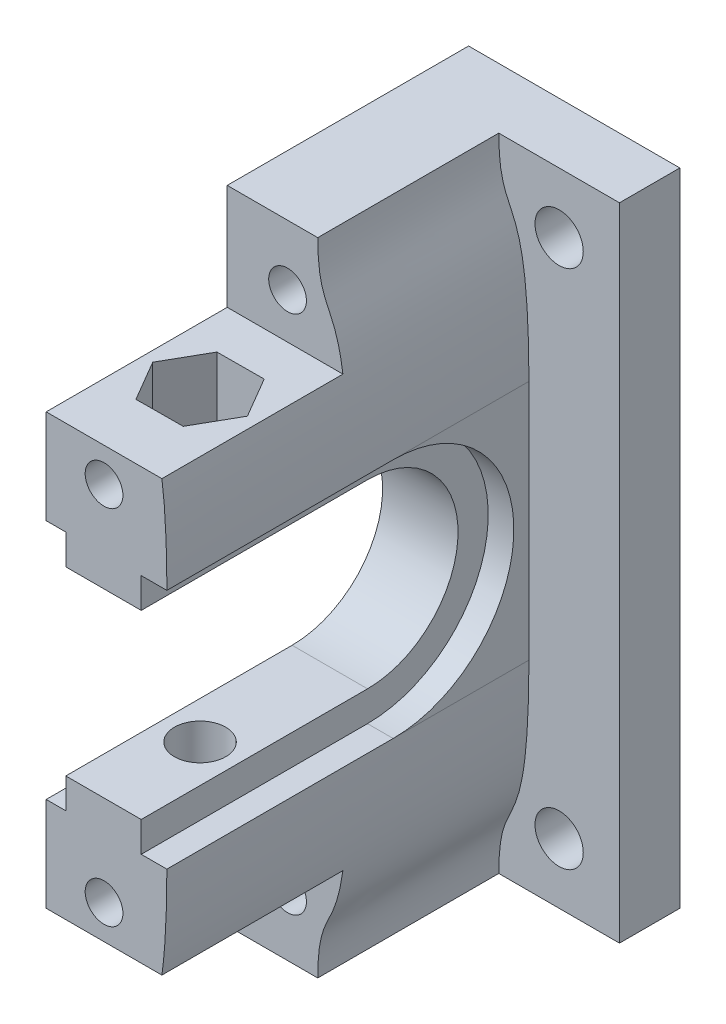
from build123d import *

# Parameters (mm, degrees)
ESQUISSE1_W                                        = 14
ESQUISSE1_H                                        = 42.5
ESQUISSE1_R                                        = 1.6
BOSS_EXTRU_1_DEPTH                                 = 4
ESQUISSE2_W                                        = 8
ESQUISSE2_H                                        = 42.5
BOSS_EXTRU_2_DEPTH                                 = 24
ENL_V_MAT_EXTRU_1_DEPTH                            = 9
ENL_V_START                                        = -1.7
ENL_V_MAT_EXTRU_3_DEPTH                            = 1.7
ENL_V_START_2                                      = -1.3
ENL_V_MAT_EXTRU_4_DEPTH                            = 1.3
ESQUISSE6_W                                        = 12
ESQUISSE6_H                                        = 7
ENL_V_MAT_EXTRU_2_DEPTH                            = 9
CHAMBRAGE_POUR_VIS_T_TE_HEXAGONALE_M31_D           = 3.4
CHAMBRAGE_POUR_VIS_T_TE_HEXAGONALE_M31_DEPTH       = 30
CHAMBRAGE_POUR_VIS_T_TE_HEXAGONALE_M31_CBORE_D     = 6.5
CHAMBRAGE_POUR_VIS_T_TE_HEXAGONALE_M31_CBORE_DEPTH = 3.4
CHAMBRAGE_POUR_VIS_T_TE_HEXAGONALE_M31_TIP         = 1.021463052
TROU_POUR_TARAUDAGE_POUR_TROU_TARAUD_M3_D          = 2.5
TROU_POUR_TARAUDAGE_POUR_TROU_TARAUD_M3_DEPTH      = 34.5
ENL_V_MAT_EXTRU_5_DEPTH                            = 4.1
ENL_V_MAT_EXTRU_6_DEPTH                            = 24
TROU_POUR_TARAUDAGE_POUR_TROU_TARAUD_2_D           = 2.5
TROU_POUR_TARAUDAGE_POUR_TROU_TARAUD_2_DEPTH       = 5


with BuildPart() as part:
    # Esquisse1 → Boss.-Extru.1 (new body)
    with BuildSketch(Plane.XY):
        with Locations((31.615489842, 21.249999998)):
            Rectangle(ESQUISSE1_W, ESQUISSE1_H)
        with Locations((34.615489842, 3.999999998)):
            Circle(ESQUISSE1_R, mode=Mode.SUBTRACT)
        with Locations((34.615489842, 38.499999998)):
            Circle(ESQUISSE1_R, mode=Mode.SUBTRACT)
    extrude(amount=BOSS_EXTRU_1_DEPTH)

    # Esquisse2 → Boss.-Extru.2 (add)
    with BuildSketch(Plane.XY.offset(4)):
        with Locations((28.615489842, 21.249999998)):
            Rectangle(ESQUISSE2_W, ESQUISSE2_H)
    extrude(amount=BOSS_EXTRU_2_DEPTH)

    # Esquisse3 → Enlèv. mat.-Extru.1 (cut, through all)
    with BuildSketch(Plane(origin=(32.615489842, 0, 0), x_dir=(0, 0, -1), z_dir=(1, 0, 0))):
        with BuildLine():
            Line((-13, 27.250000778), (-28, 27.250000778))
            Line((-28, 27.250000778), (-28, 15.250000778))
            Line((-28, 15.250000778), (-13, 15.250000778))
            ThreePointArc((-13, 15.250000778), (-7, 21.250000778), (-13, 27.250000778))
        make_face()
    extrude(amount=-ENL_V_MAT_EXTRU_1_DEPTH, mode=Mode.SUBTRACT)

    # Esquisse7 → Enlèv. mat.-Extru.3 (cut)
    with BuildSketch(Plane(origin=(32.615489842, 0, 0), x_dir=(0, 0, -1), z_dir=(1, 0, 0)).offset(ENL_V_START)):
        with BuildLine():
            Line((-13, 13.250000429), (-28, 13.250000429))
            Line((-28, 13.250000429), (-28, 29.250000429))
            Line((-28, 29.250000429), (-13, 29.250000429))
            ThreePointArc((-13, 29.250000429), (-5, 21.250000429), (-13, 13.250000429))
        make_face()
    extrude(amount=ENL_V_MAT_EXTRU_3_DEPTH, mode=Mode.SUBTRACT)

    # Esquisse8 → Enlèv. mat.-Extru.4 (cut)
    with BuildSketch(Plane.ZY.offset(-24.615489842).offset(ENL_V_START_2)):
        with BuildLine():
            Line((13, 13.250000429), (28, 13.250000429))
            Line((28, 13.250000429), (28, 29.250000429))
            Line((28, 29.250000429), (13, 29.250000429))
            ThreePointArc((13, 29.250000429), (5, 21.250000429), (13, 13.250000429))
        make_face()
    extrude(amount=ENL_V_MAT_EXTRU_4_DEPTH, mode=Mode.SUBTRACT)

    # Esquisse6 → Enlèv. mat.-Extru.2 (cut, through all)
    with BuildSketch(Plane(origin=(32.615489842, 0, 0), x_dir=(0, 0, -1), z_dir=(1, 0, 0))):
        with Locations((-22, 38.999999998)):
            Rectangle(ESQUISSE6_W, ESQUISSE6_H)
        Polygon((-28, -2e-09), (-16, 0), (-16, 7), (-28, 7), align=None)
    extrude(amount=-ENL_V_MAT_EXTRU_2_DEPTH, mode=Mode.SUBTRACT)

    # Chambrage pour vis à tête hexagonale M31
    with Locations(Plane(origin=(0, 7, 0), x_dir=(-1, 0, 0), z_dir=(0, -1, 0))):
        with Locations((-28.415489842, -21.6)):
            CounterBoreHole(CHAMBRAGE_POUR_VIS_T_TE_HEXAGONALE_M31_D / 2, CHAMBRAGE_POUR_VIS_T_TE_HEXAGONALE_M31_CBORE_D / 2, CHAMBRAGE_POUR_VIS_T_TE_HEXAGONALE_M31_CBORE_DEPTH, depth=CHAMBRAGE_POUR_VIS_T_TE_HEXAGONALE_M31_DEPTH)
            with Locations((0, 0, -(CHAMBRAGE_POUR_VIS_T_TE_HEXAGONALE_M31_DEPTH + CHAMBRAGE_POUR_VIS_T_TE_HEXAGONALE_M31_TIP / 2))):  # 118° drill point
                Cone(0, CHAMBRAGE_POUR_VIS_T_TE_HEXAGONALE_M31_D / 2, CHAMBRAGE_POUR_VIS_T_TE_HEXAGONALE_M31_TIP, mode=Mode.SUBTRACT)

    # Trou pour taraudage pour trou taraud_ M3
    with Locations(Plane.XY.offset(16)):
        with Locations((28.615489842, 4), (28.615489842, 38.499999998)):
            Hole(TROU_POUR_TARAUDAGE_POUR_TROU_TARAUD_M3_D / 2, depth=TROU_POUR_TARAUDAGE_POUR_TROU_TARAUD_M3_DEPTH)

    # Esquisse15 → Enlèv. mat.-Extru.5 (cut)
    with BuildSketch(Plane(origin=(0, 35.499999998, 0), x_dir=(1, 0, 0), z_dir=(0, 1, 0))):
        Polygon((25.297858374, -21.619339993), (26.873423034, -24.309618047), (29.991054501, -24.290278053), (31.533121309, -21.580660007), (29.95755665, -18.890381953), (26.839925183, -18.909721947), align=None)
    extrude(amount=-ENL_V_MAT_EXTRU_5_DEPTH, mode=Mode.SUBTRACT)

    # Esquisse16 → Enlèv. mat.-Extru.6 (cut)
    with BuildSketch(Plane.XY.offset(28)):
        with BuildLine():
            Line((30.615489842, 0), (32.615489842, -2e-09))
            Line((32.615489842, -2e-09), (32.615489842, 13.250000429))
            add(Edge.make_bspline(
                [(32.615489842, 13.250000429), (32.591528482, 1.687598594), (30.638844219, 5.520365059), (30.615489842, 0)],
                knots=[0, 0, 0, 0, 1, 1, 1, 1], degree=3))
        make_face()
        with BuildLine():
            Line((30.615489842, 42.500000857), (32.615489842, 42.50000086))
            Line((32.615489842, 42.50000086), (32.615489842, 29.250000429))
            add(Edge.make_bspline(
                [(32.615489842, 29.250000429), (32.591528482, 40.812402263), (30.638844219, 36.979635798), (30.615489842, 42.500000857)],
                knots=[0, 0, 0, 0, 1, 1, 1, 1], degree=3))
        make_face()
    extrude(amount=-ENL_V_MAT_EXTRU_6_DEPTH, mode=Mode.SUBTRACT)

    # Trou pour taraudage pour trou taraud 2
    with Locations(Plane.XY.offset(28)):
        with Locations((28.450357355, 33.249999999), (28.450357355, 9.249999999)):
            Hole(TROU_POUR_TARAUDAGE_POUR_TROU_TARAUD_2_D / 2, depth=TROU_POUR_TARAUDAGE_POUR_TROU_TARAUD_2_DEPTH)


solid = part.part
